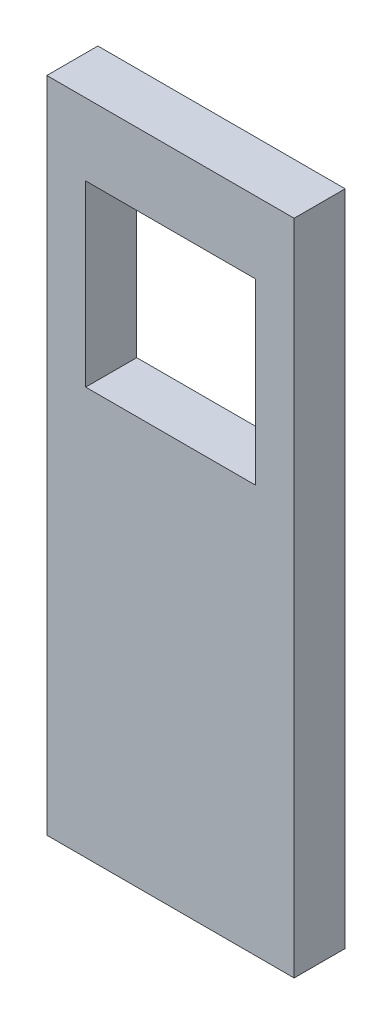
from build123d import *

# Parameters (mm, degrees)
SKETCH1_W           = 17.28
SKETCH1_H           = 18.2
BOSS_EXTRUDE1_DEPTH = 2.6


with BuildPart() as part:
    # Sketch1 → Boss-Extrude1 (new body, symmetric)
    with BuildSketch(Plane.XY):
        Polygon((-0.1, 66.95), (-0.1, 44.55), (-0.1, 39.4), (-0.1, 27.45), (-0.1, 22.3), (-0.1, -0.1), (25.1, -0.1), (25.1, 22.3), (25.1, 27.45), (25.1, 39.4), (25.1, 44.55), (25.1, 66.95), align=None)
        with Locations((12.5, 50.525)):
            Rectangle(SKETCH1_W, SKETCH1_H, mode=Mode.SUBTRACT)
    extrude(amount=BOSS_EXTRUDE1_DEPTH, both=True)


solid = part.part
